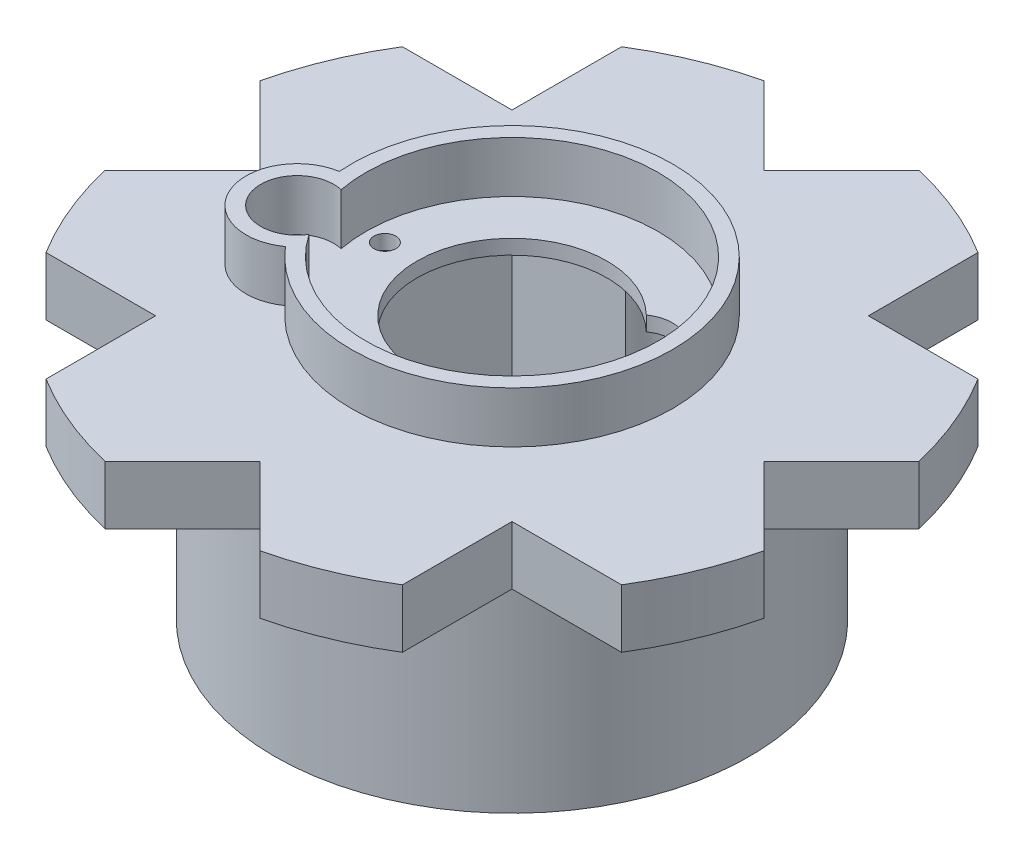
from build123d import *

# Parameters (mm, degrees)
SKETCH3_R           = 1.5
CUT_EXTRUDE1_DEPTH  = 20
BOSS_EXTRUDE2_START = 36
BOSS_EXTRUDE2_DEPTH = 8
CIRPATTERN1_COUNT   = 8
SKETCH5_R           = 4.669864721
CUT_EXTRUDE2_DEPTH  = 37
CUT_EXTRUDE4_DEPTH  = 34
CUT_EXTRUDE4_DRAFT  = -0.5
BOSS_EXTRUDE3_DEPTH = 7


with BuildPart() as part:
    # Sketch2 → Revolve1 (revolve)
    with BuildSketch(Plane.XY):
        Polygon((13, 0), (13, 36), (22.5, 36), (32.5, 36), (32.5, 0), align=None)
    revolve(axis=Axis((0, 0, 0), (0, 1, 0)))

    # Sketch3 → Cut-Extrude1 (cut)
    with BuildSketch(Plane(origin=(0, 36, 0), x_dir=(1, 0, 0), z_dir=(0, 1, 0))):
        with Locations((-17.4, 0)):
            Circle(SKETCH3_R)
        with Locations((17.4, 0)):
            Circle(SKETCH3_R)
    extrude(amount=-CUT_EXTRUDE1_DEPTH, mode=Mode.SUBTRACT)

    # Sketch4 → Boss-Extrude2 (add)
    with BuildSketch(Plane(origin=(0, 0, 0), x_dir=(1, 0, 0), z_dir=(0, 1, 0)).offset(BOSS_EXTRUDE2_START)):
        with BuildLine():
            Line((0, 34.5), (-10.606601718, 45.106601718))
            ThreePointArc((-10.606601718, 45.106601718), (-14.215943039, 44.102295655), (-17.732352445, 42.809685765))
            Line((-17.732352445, 42.809685765), (-12.437211552, 30.026084807))
            ThreePointArc((-12.437211552, 30.026084807), (0, 32.5), (12.437211552, 30.026084807))
            Line((12.437211552, 30.026084807), (17.732352445, 42.809685765))
            ThreePointArc((17.732352445, 42.809685765), (14.215943039, 44.102295655), (10.606601718, 45.106601718))
            Line((10.606601718, 45.106601718), (0, 34.5))
        make_face()
    boss_extrude2 = extrude(amount=-BOSS_EXTRUDE2_DEPTH)

    # CirPattern1: Boss-Extrude2 ×8 about axis
    cirpattern1_axis = Axis((0, 0, 0), (0, 1, 0))
    for i in range(1, CIRPATTERN1_COUNT):
        add(boss_extrude2.rotate(cirpattern1_axis, i * 360 / CIRPATTERN1_COUNT))

    # Sketch5 → Cut-Extrude2 (cut, through all)
    with BuildSketch(Plane(origin=(0, 36, 0), x_dir=(1, 0, 0), z_dir=(0, 1, 0))):
        with Locations((11.791900395, 5.472758453)):
            Circle(SKETCH5_R)
    extrude(amount=-CUT_EXTRUDE2_DEPTH, mode=Mode.SUBTRACT)


with BuildPart() as cut_extrude4_tool:
    # Sketch8 → Cut-Extrude4 (with draft: the straight prism first)
    with BuildSketch(Plane.XZ):
        with BuildLine():
            Line((-19.5, 19.5), (-19.5, -19.5))
            Line((-19.5, -19.5), (-4, -19.5))
            ThreePointArc((-4, -19.5), (0, -23.5), (4, -19.5))
            Line((4, -19.5), (19.5, -19.5))
            Line((19.5, -19.5), (19.5, 19.5))
            Line((19.5, 19.5), (-19.5, 19.5))
        make_face()
    extrude(amount=-CUT_EXTRUDE4_DEPTH)
    # Cut-Extrude4: the draft: its side faces are tilted about the plane it starts from
    cut_extrude4_sides = [cut_extrude4_tool.faces().sort_by_distance(p)[0] for p in [
        (-19.5, 17, 0),
        (-11.75, 17, -19.5),
        (0, 17, -23.5),
        (11.75, 17, -19.5),
        (19.5, 17, 0),
        (0, 17, 19.5),
    ]]
    draft(cut_extrude4_sides, Plane.XZ, CUT_EXTRUDE4_DRAFT)


with BuildPart() as part_1:
    add(part.part)

    # Cut-Extrude4: cut by cut_extrude4_tool
    add(cut_extrude4_tool.part, mode=Mode.SUBTRACT)

    # Sketch9 → Boss-Extrude3 (add)
    with BuildSketch(Plane(origin=(0, 36, 0), x_dir=(1, 0, 0), z_dir=(0, 1, 0))):
        with BuildLine():
            ThreePointArc((-16.715121997, -14.30400981), (20.325349715, 8.419035512), (-21.933838447, -1.704913777))
            ThreePointArc((-21.933838447, -1.704913777), (-27.254446209, -11.289161255), (-16.715121997, -14.30400981))
        make_face()
        with BuildLine():
            ThreePointArc((-19.646781143, -3.742190633), (-25.406687144, -10.52379439), (-16.538500547, -11.246243802))
            ThreePointArc((-16.538500547, -11.246243802), (18.47759065, 7.653668647), (-19.646781143, -3.742190633))
        make_face(mode=Mode.SUBTRACT)
    extrude(amount=BOSS_EXTRUDE3_DEPTH)


solid = part_1.part
